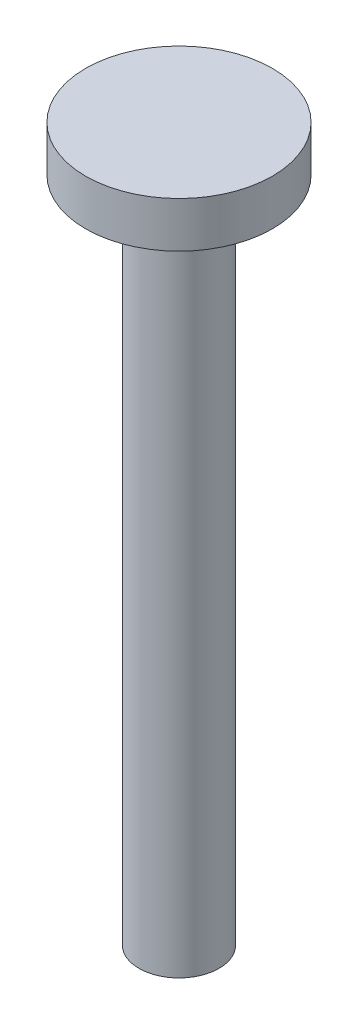
from build123d import *

# Parameters (mm, degrees)
SKETCH_1_R      = 3.5
EXTRUDE_1_DEPTH = 1.71
SKETCH_2_R      = 1.5
EXTRUDE_2_DEPTH = 25


with BuildPart() as part:
    # 草图1 → 凸台-拉伸1 (new body)
    with BuildSketch(Plane(origin=(0, 0, 0), x_dir=(1, 0, 0), z_dir=(0, 1, 0))):
        Circle(SKETCH_1_R)
    extrude(amount=EXTRUDE_1_DEPTH)

    # 草图2 → 凸台-拉伸2 (add)
    with BuildSketch(Plane.XZ):
        Circle(SKETCH_2_R)
    extrude(amount=EXTRUDE_2_DEPTH)


solid = part.part
